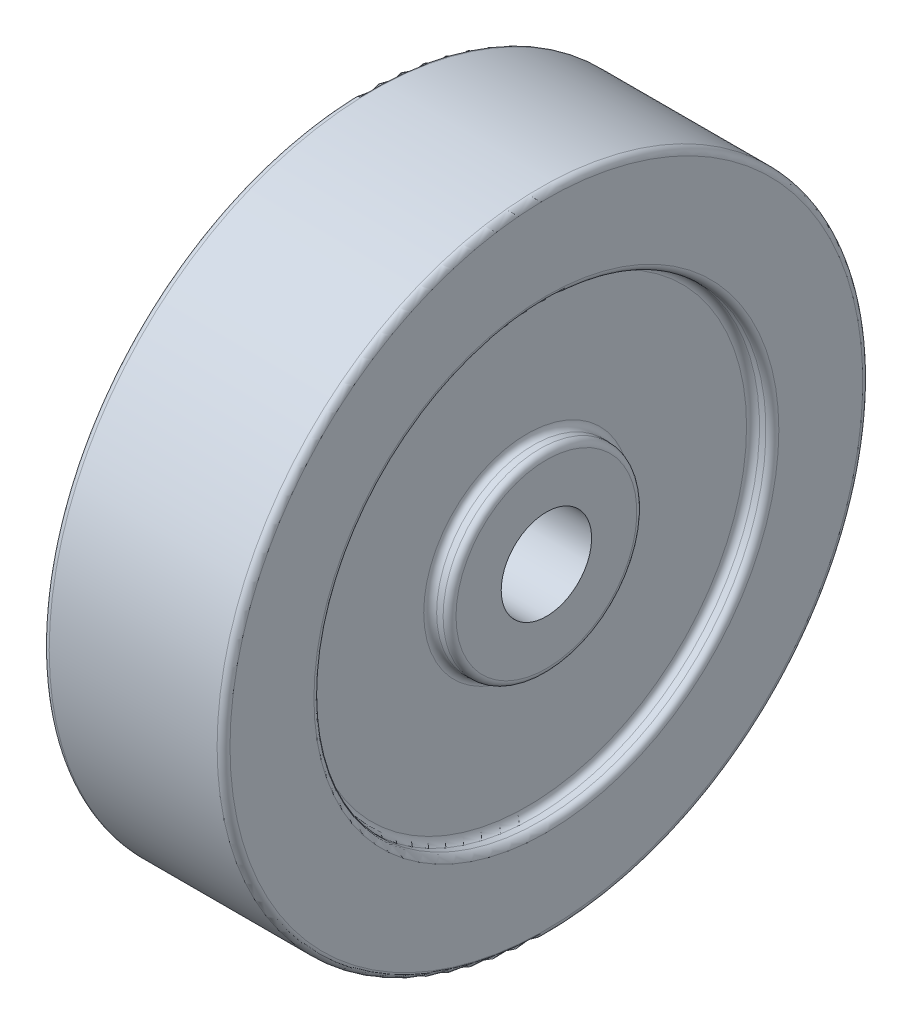
from build123d import *

# Parameters (mm, degrees)
FILLET1_R = 1


with BuildPart() as part:
    # Sketch1 → Revolve1 (revolve)
    with BuildSketch(Plane.XY):
        Polygon((14, 7), (14, 15), (11, 15), (11, 35), (14, 35), (14, 50), (-14, 50), (-14, 35), (-11, 35), (-11, 15), (-14, 15), (-14, 7), align=None)
    revolve(axis=Axis((-90.072289157, 0, 0), (1, 0, 0)))

    # Fillet1
    fillet1_edges = [part.edges().sort_by_distance(p)[0] for p in [
        (-11, -15, 0),
        (-11, -35, 0),
        (-14, -35, 0),
        (-14, -50, 0),
        (14, -50, 0),
        (14, -35, 0),
        (11, -35, 0),
        (11, -15, 0),
        (14, -15, 0),
        (-14, -15, 0),
    ]]
    fillet(fillet1_edges, radius=FILLET1_R)


solid = part.part
